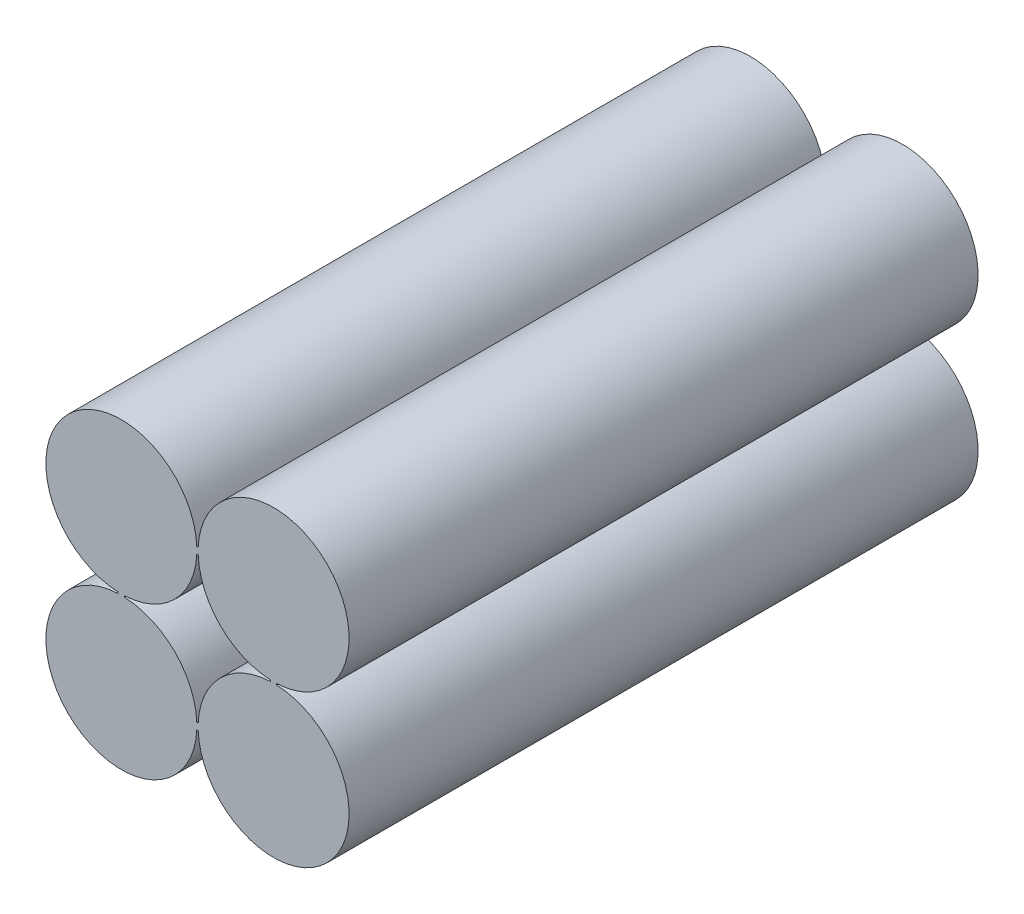
from build123d import *

# Parameters (mm, degrees)
BOSS_EXTRUDE1_DEPTH = 50


with BuildPart() as part:
    # Sketch1 → Boss-Extrude1 (new body)
    with BuildSketch(Plane.XY):
        with BuildLine():
            Line((5.994789404, 0.25), (6.105210596, 0.25))
            ThreePointArc((6.105210596, 0.25), (16.342640687, 4.242640687), (12.35, -5.994789404))
            Line((12.35, -5.994789404), (12.35, -6.105210596))
            ThreePointArc((12.35, -6.105210596), (16.342640687, -16.342640687), (6.105210596, -12.35))
            Line((6.105210596, -12.35), (5.994789404, -12.35))
            ThreePointArc((5.994789404, -12.35), (-4.242640687, -16.342640687), (-0.25, -6.105210596))
            Line((-0.25, -6.105210596), (-0.25, -5.994789404))
            ThreePointArc((-0.25, -5.994789404), (-4.242640687, 4.242640687), (5.994789404, 0.25))
        make_face()
        with BuildLine():
            Line((5.994789404, -0.25), (6.105210596, -0.25))
            ThreePointArc((6.105210596, -0.25), (7.857359313, -4.242640687), (11.85, -5.994789404))
            Line((11.85, -5.994789404), (11.85, -6.105210596))
            ThreePointArc((11.85, -6.105210596), (7.857359313, -7.857359313), (6.105210596, -11.85))
            Line((6.105210596, -11.85), (5.994789404, -11.85))
            ThreePointArc((5.994789404, -11.85), (4.242640687, -7.857359313), (0.25, -6.105210596))
            Line((0.25, -6.105210596), (0.25, -5.994789404))
            ThreePointArc((0.25, -5.994789404), (4.242640687, -4.242640687), (5.994789404, -0.25))
        make_face(mode=Mode.SUBTRACT)
    extrude(amount=BOSS_EXTRUDE1_DEPTH)


solid = part.part
